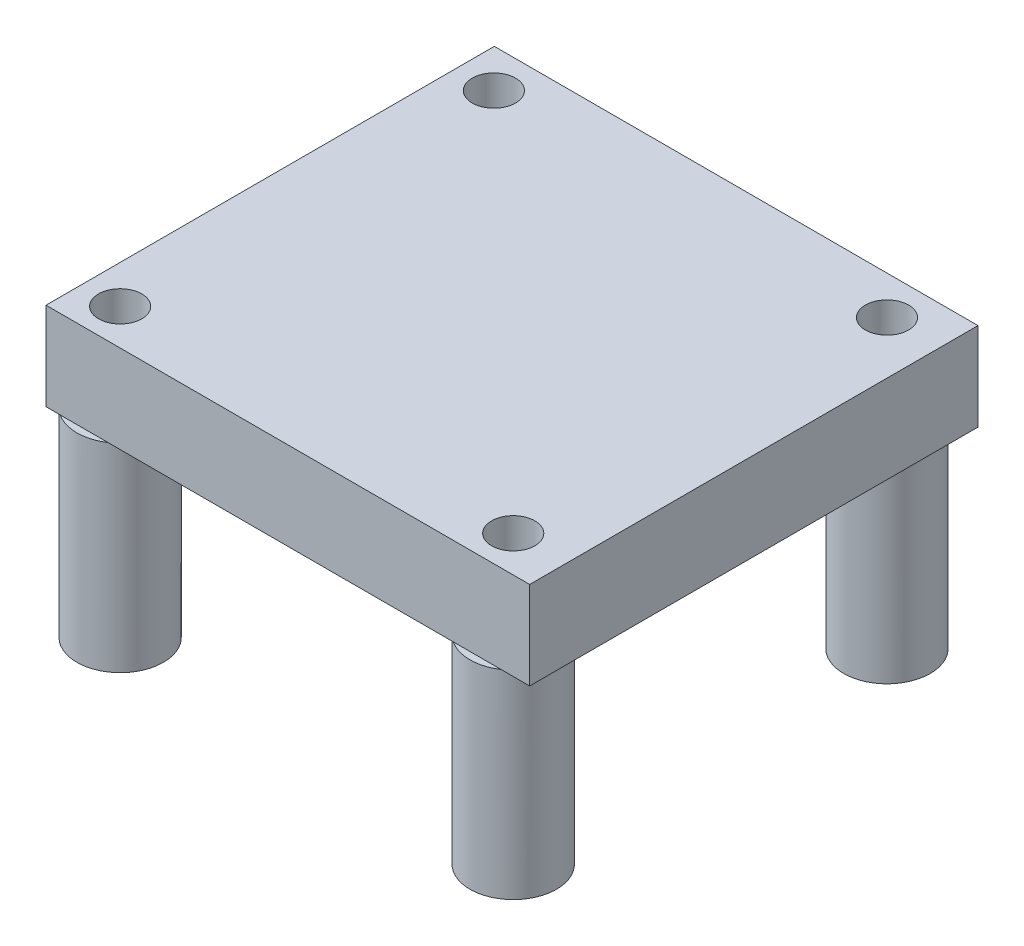
from build123d import *

# Parameters (mm, degrees)
SKETCH1_W               = 27.94
SKETCH1_H               = 25.9
BOSS_EXTRUDE1_DEPTH     = 5.08
SKETCH2_R               = 2.5
SKETCH2_R_2             = 1.25
BOSS_EXTRUDE2_DEPTH     = 11.4808
SKETCH3_R               = 1.25
CUT_EXTRUDE1_DEPTH      = 1
CUT_EXTRUDE1_DEPTH_BACK = 17.5608


with BuildPart() as part:
    # Sketch1 → Boss-Extrude1 (new body)
    with BuildSketch(Plane(origin=(0, 0, 0), x_dir=(1, 0, 0), z_dir=(0, 1, 0))):
        with Locations((2.687100719, -2.320830935)):
            Rectangle(SKETCH1_W, SKETCH1_H)
    extrude(amount=BOSS_EXTRUDE1_DEPTH)

    # Sketch2 → Boss-Extrude2 (add)
    with BuildSketch(Plane.XZ):
        with Locations((-9.082699611, 13.186946911)):
            Circle(SKETCH2_R)
        with Locations((-9.082699611, 13.186946911)):
            Circle(SKETCH2_R_2, mode=Mode.SUBTRACT)
        with Locations((13.624900389, 13.186946911)):
            Circle(SKETCH2_R)
        with Locations((13.624900389, 13.186946911)):
            Circle(SKETCH2_R_2, mode=Mode.SUBTRACT)
        with Locations((-9.082699611, -8.403053089)):
            Circle(SKETCH2_R)
        with Locations((-9.082699611, -8.403053089)):
            Circle(SKETCH2_R_2, mode=Mode.SUBTRACT)
        with Locations((13.624900389, -8.403053089)):
            Circle(SKETCH2_R)
        with Locations((13.624900389, -8.403053089)):
            Circle(SKETCH2_R_2, mode=Mode.SUBTRACT)
    extrude(amount=BOSS_EXTRUDE2_DEPTH)

    # Sketch3 → Cut-Extrude1 (cut, two sides)
    with BuildSketch(Plane(origin=(0, 5.08, 0), x_dir=(1, 0, 0), z_dir=(0, 1, 0))) as cut_extrude1_sk:
        with Locations((13.624900389, 8.403053089)):
            Circle(SKETCH3_R)
        with Locations((-9.082699611, 8.403053089)):
            Circle(SKETCH3_R)
        with Locations((13.624900389, -13.186946911)):
            Circle(SKETCH3_R)
        with Locations((-9.082699611, -13.186946911)):
            Circle(SKETCH3_R)
    extrude(amount=CUT_EXTRUDE1_DEPTH, mode=Mode.SUBTRACT)
    extrude(cut_extrude1_sk.sketch, amount=-CUT_EXTRUDE1_DEPTH_BACK, mode=Mode.SUBTRACT)


solid = part.part
